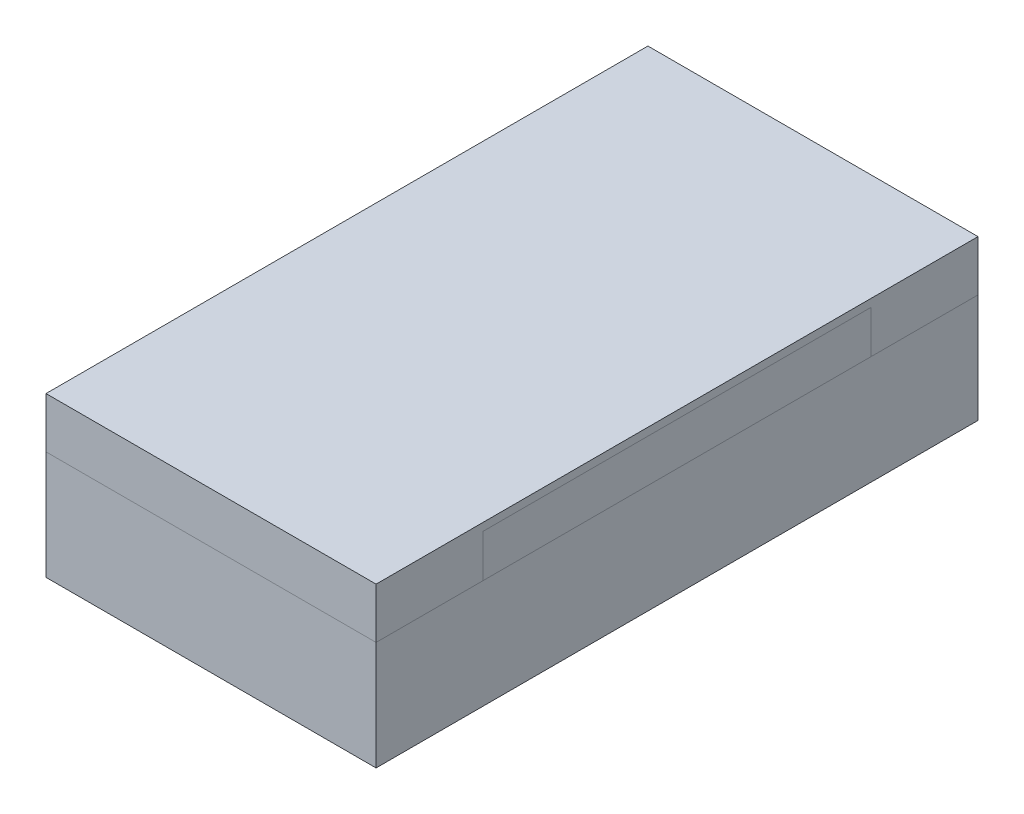
from build123d import *

# Parameters (mm, degrees)
SKETCH1_W           = 0.85
SKETCH1_H           = 1.55
BOSS_EXTRUDE1_DEPTH = 0.28
SKETCH2_W           = 0.85
SKETCH2_H           = 1
BOSS_EXTRUDE2_DEPTH = 0.11
SKETCH3_W           = 0.85
SKETCH3_H           = 1
BOSS_EXTRUDE3_DEPTH = 0.02
SKETCH4_W           = 0.85
SKETCH4_H           = 0.275
BOSS_EXTRUDE5_DEPTH = 0.13


with BuildPart() as part:
    # Sketch1 → Boss-Extrude1 (new body)
    with BuildSketch(Plane(origin=(0, 0, 0), x_dir=(1, 0, 0), z_dir=(0, 1, 0))):
        Rectangle(SKETCH1_W, SKETCH1_H)
    extrude(amount=BOSS_EXTRUDE1_DEPTH)


with BuildPart() as body_2:
    # Sketch2 → Boss-Extrude2 (new body)
    with BuildSketch(Plane(origin=(0, 0.28, 0), x_dir=(1, 0, 0), z_dir=(0, 1, 0))):
        Rectangle(SKETCH2_W, SKETCH2_H)
    extrude(amount=BOSS_EXTRUDE2_DEPTH)


with BuildPart() as body_3:
    # Sketch3 → Boss-Extrude3 (new body)
    with BuildSketch(Plane(origin=(0, 0.39, 0), x_dir=(1, 0, 0), z_dir=(0, 1, 0))):
        Rectangle(SKETCH3_W, SKETCH3_H)
    extrude(amount=BOSS_EXTRUDE3_DEPTH)

    # Sketch4 → Boss-Extrude5 (add)
    with BuildSketch(Plane(origin=(0, 0.28, 0), x_dir=(1, 0, 0), z_dir=(0, 1, 0))):
        with Locations((0, 0.6375)):
            Rectangle(SKETCH4_W, SKETCH4_H)
        with Locations((0, -0.6375)):
            Rectangle(SKETCH4_W, SKETCH4_H)
    extrude(amount=BOSS_EXTRUDE5_DEPTH)


solid = Compound([part.part, body_2.part, body_3.part])
